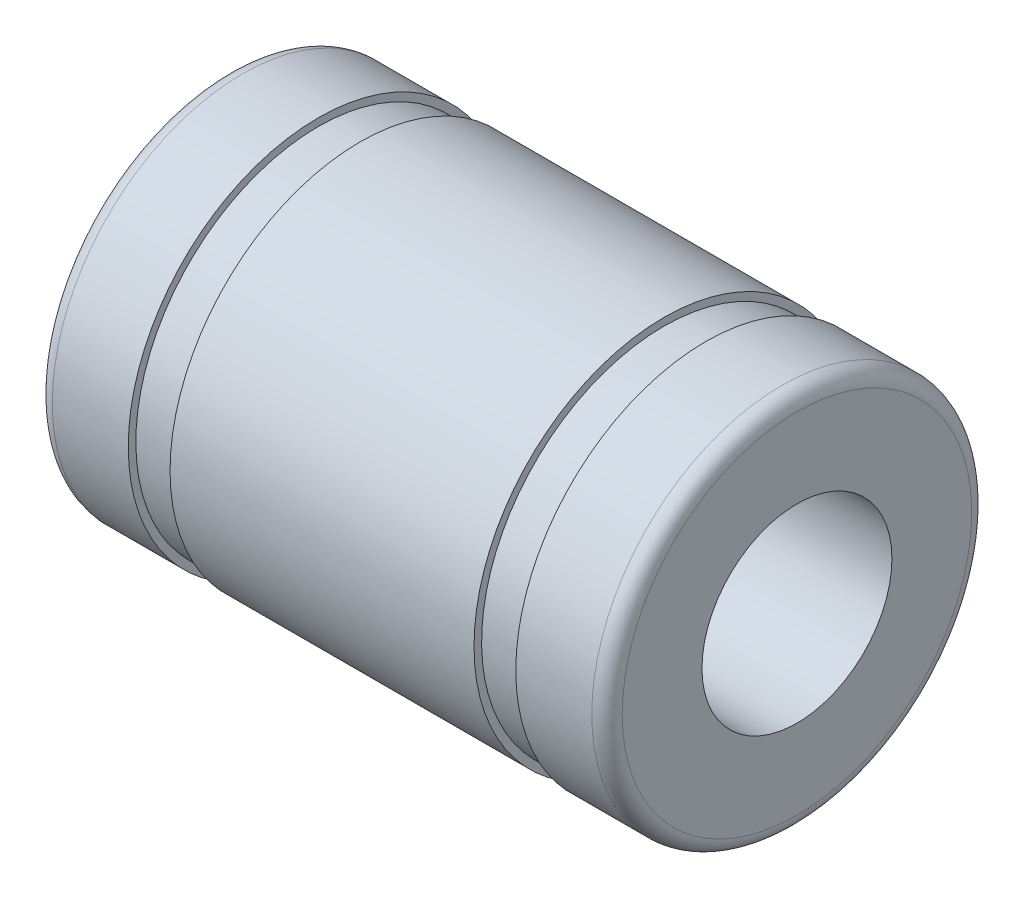
from build123d import *

# Parameters (mm, degrees)
SKETCH1_W = 15
SKETCH1_H = 2.5
FILLET1_R = 0.4
SKETCH2_W = 1.1
SKETCH2_H = 0.2


with BuildPart() as part:
    # Sketch1 → Revolve1 (revolve)
    with BuildSketch(Plane.XY):
        with Locations((7.5, 3.75)):
            Rectangle(SKETCH1_W, SKETCH1_H)
    revolve(axis=Axis((0, 0, 0), (1, 0, 0)))

    # Fillet1
    fillet1_edges = [part.edges().sort_by_distance(p)[0] for p in [
        (0, -5, 0),
        (15, -5, 0),
    ]]
    fillet(fillet1_edges, radius=FILLET1_R)

    # Sketch2 → Cut-Revolve1 (revolve, cut)
    with BuildSketch(Plane.XY):
        with Locations((12.05, 4.9)):
            Rectangle(SKETCH2_W, SKETCH2_H)
        with Locations((2.95, 4.9)):
            Rectangle(SKETCH2_W, SKETCH2_H)
    revolve(axis=Axis((15, 0, 0), (-1, 0, 0)), mode=Mode.SUBTRACT)


solid = part.part
